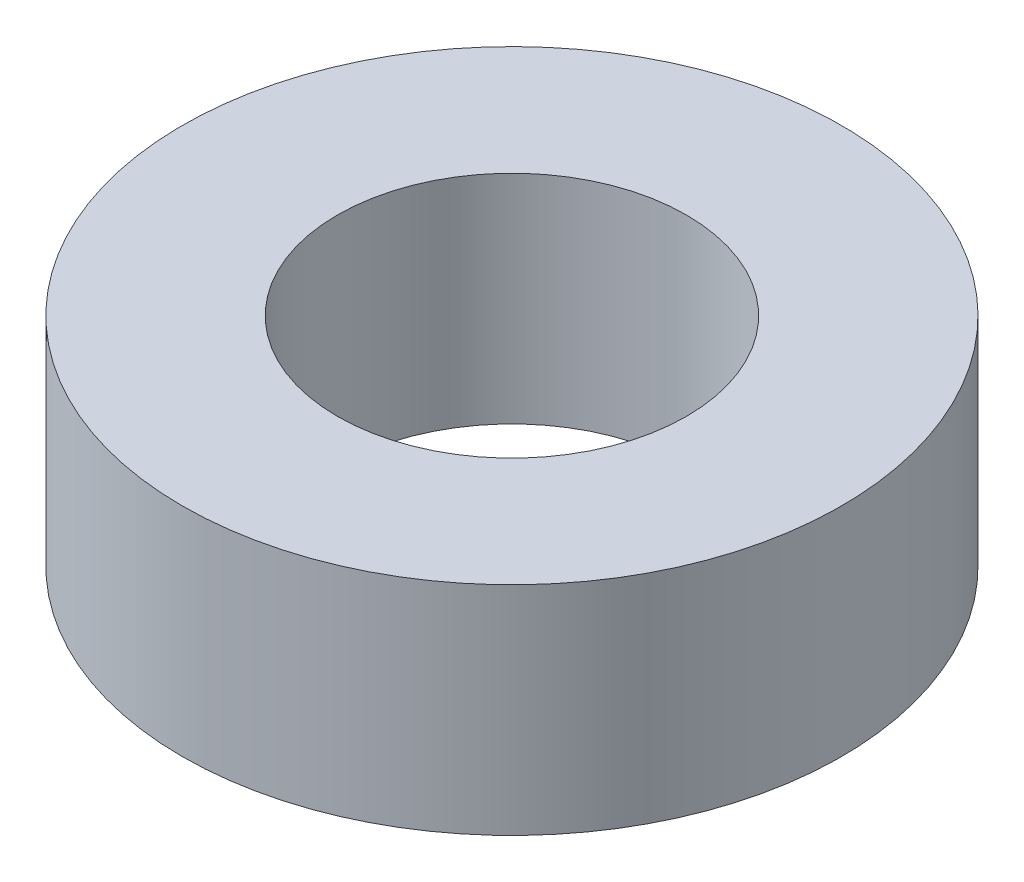
from build123d import *

# Parameters (mm, degrees)
SKETCH1_R           = 10.795
SKETCH1_R_2         = 5.715
BOSS_EXTRUDE1_DEPTH = 7.112


with BuildPart() as part:
    # Sketch1 → Boss-Extrude1 (new body)
    with BuildSketch(Plane(origin=(0, 0, 0), x_dir=(1, 0, 0), z_dir=(0, 1, 0))):
        Circle(SKETCH1_R)
        Circle(SKETCH1_R_2, mode=Mode.SUBTRACT)
    extrude(amount=BOSS_EXTRUDE1_DEPTH)


solid = part.part
